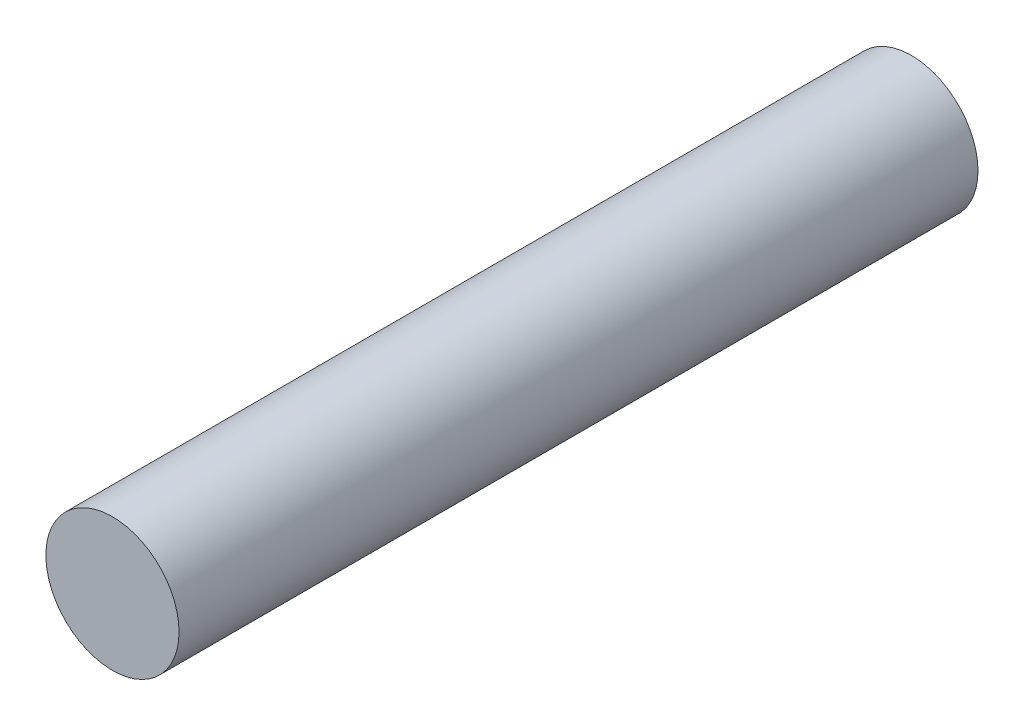
from build123d import *

# Parameters (mm, degrees)
SKETCH1_R           = 6.35
BOSS_EXTRUDE1_DEPTH = 76.2


with BuildPart() as part:
    # Sketch1 → Boss-Extrude1 (new body)
    with BuildSketch(Plane.XY):
        Circle(SKETCH1_R)
    extrude(amount=BOSS_EXTRUDE1_DEPTH)


solid = part.part
